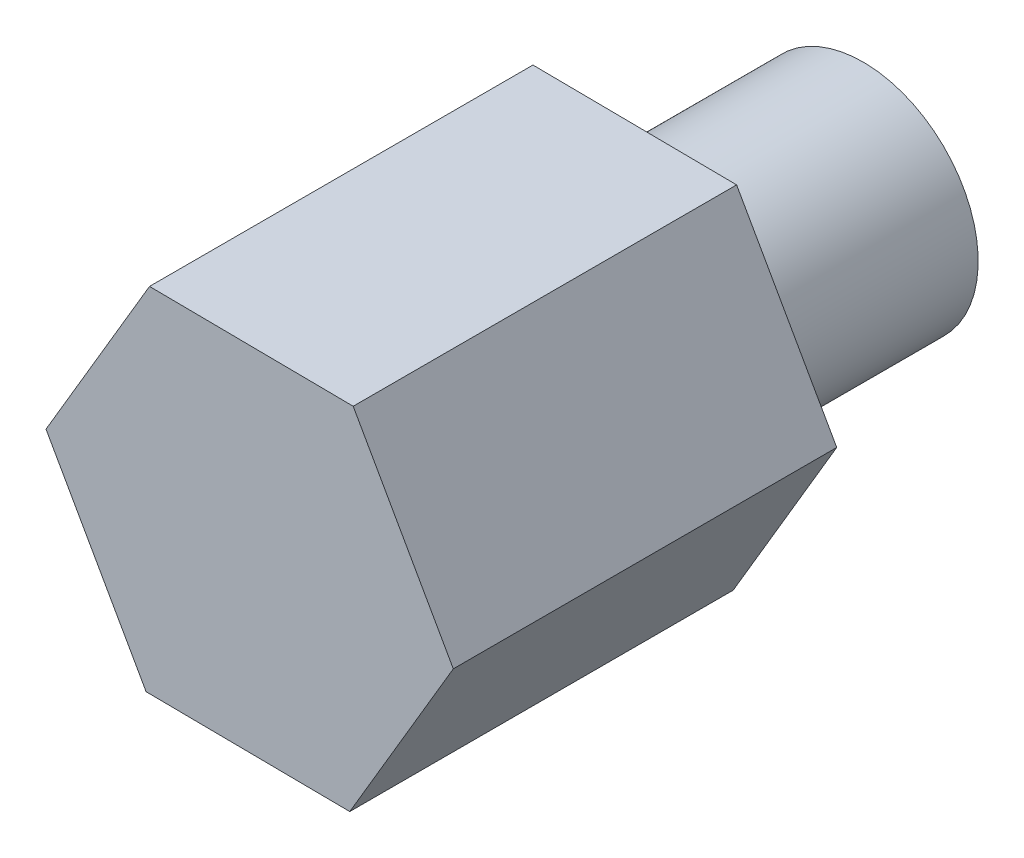
from build123d import *

# Parameters (mm, degrees)
EXTRUDE_1_DEPTH = 5
SKETCH_2_R      = 1.5
EXTRUDE_2_DEPTH = 3


with BuildPart() as part:
    # 草图1 → 凸台-拉伸1 (new body)
    with BuildSketch(Plane.XY):
        Polygon((1.305558507, -2.312758163), (2.655686575, -0.025732248), (1.350128068, 2.287025914), (-1.305558507, 2.312758163), (-2.655686575, 0.025732248), (-1.350128068, -2.287025914), align=None)
    extrude(amount=EXTRUDE_1_DEPTH)

    # 草图2 → 凸台-拉伸2 (add)
    with BuildSketch(Plane(origin=(0, 0, 0), x_dir=(-1, 0, 0), z_dir=(0, 0, -1))):
        Circle(SKETCH_2_R)
    extrude(amount=EXTRUDE_2_DEPTH)


solid = part.part
